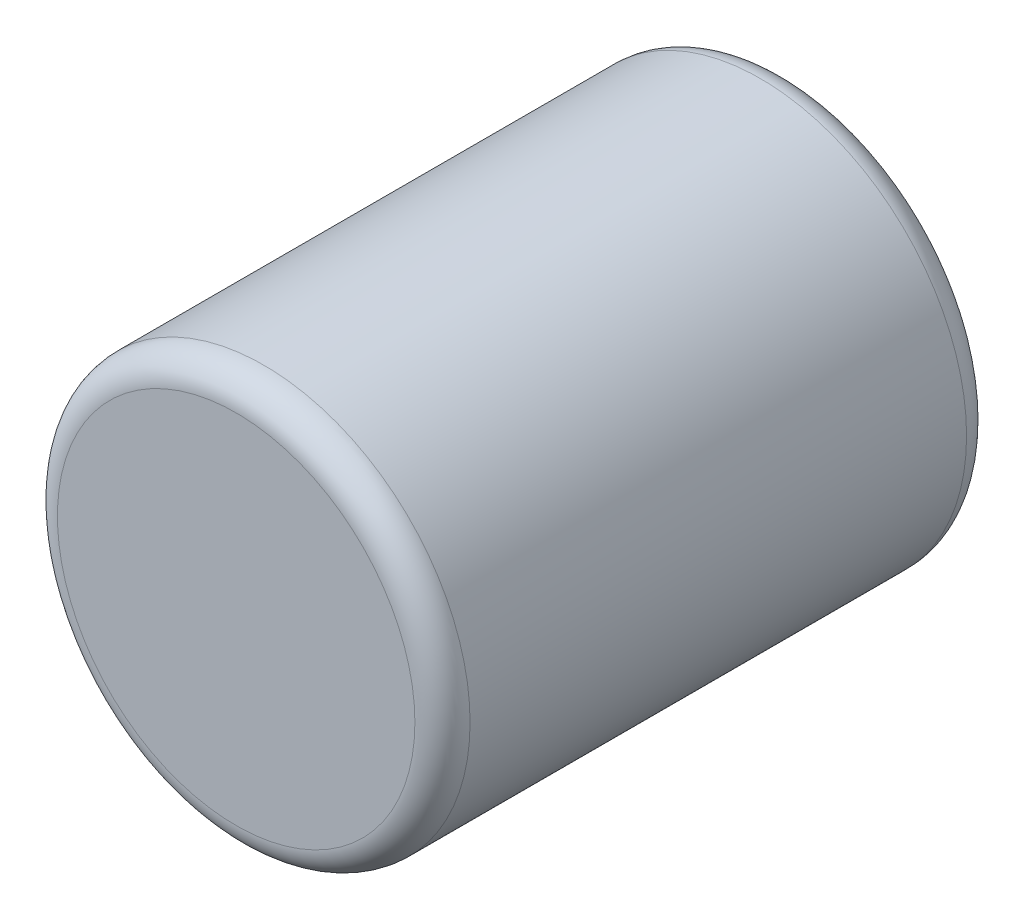
from build123d import *

# Parameters (mm, degrees)
SKETCH1_R           = 47.498
BOSS_EXTRUDE1_DEPTH = 127
FILLET1_R           = 6.35


with BuildPart() as part:
    # Sketch1 → Boss-Extrude1 (new body)
    with BuildSketch(Plane.XY):
        Circle(SKETCH1_R)
    extrude(amount=-BOSS_EXTRUDE1_DEPTH)

    # Fillet1
    fillet1_edges = [part.edges().sort_by_distance(p)[0] for p in [
        (-47.498, 0, 0),
        (-47.498, 0, -127),
    ]]
    fillet(fillet1_edges, radius=FILLET1_R)


solid = part.part
